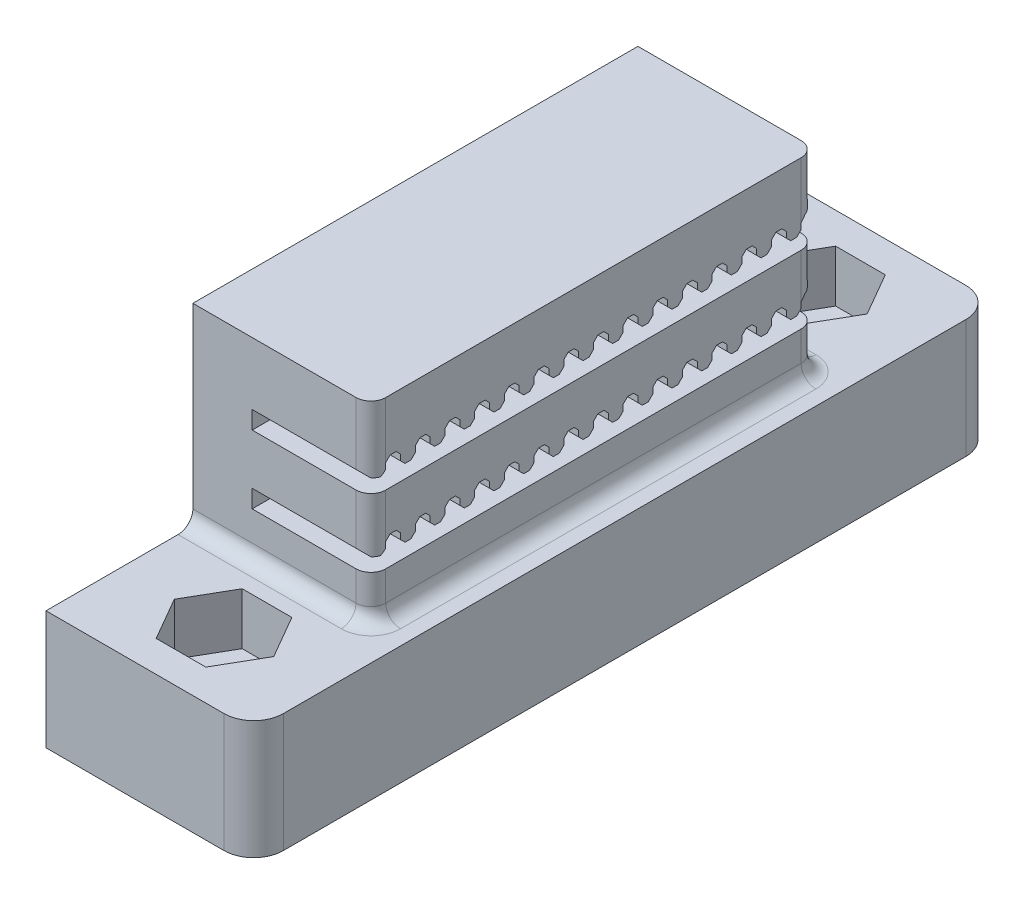
from build123d import *

# Parameters (mm, degrees)
CROQUIS1_W              = 14
CROQUIS1_H              = 50
CROQUIS1_R              = 1.65
SALIENTE_EXTRUIR1_DEPTH = 8
CORTAR_EXTRUIR1_DEPTH   = 3.5
CROQUIS3_W              = 14
CROQUIS3_H              = 30
SALIENTE_EXTRUIR3_DEPTH = 13
CORTAR_EXTRUIR2_DEPTH   = 10
CROQUIS5_W              = 30
CROQUIS5_H              = 13
CORTAR_EXTRUIR3_DEPTH   = 2
REDONDEO2_R             = 2
REDONDEO3_R             = 1
REDONDEO4_R             = 1


with BuildPart() as part:
    # Croquis1 → Saliente-Extruir1 (new body)
    with BuildSketch(Plane(origin=(0, 0, 0), x_dir=(1, 0, 0), z_dir=(0, 1, 0))):
        with Locations((7, 25)):
            Rectangle(CROQUIS1_W, CROQUIS1_H)
        with Locations((7, 45)):
            Circle(CROQUIS1_R, mode=Mode.SUBTRACT)
        with Locations((7, 5)):
            Circle(CROQUIS1_R, mode=Mode.SUBTRACT)
    extrude(amount=SALIENTE_EXTRUIR1_DEPTH)

    # Croquis2 → Cortar-Extruir1 (cut)
    with BuildSketch(Plane(origin=(0, 8, 0), x_dir=(1, 0, 0), z_dir=(0, 1, 0))):
        Polygon((10.348631561, 45), (8.674315781, 47.9), (5.325684219, 47.9), (3.651368439, 45), (5.325684219, 42.1), (8.674315781, 42.1), align=None)
        Polygon((10.348631561, 5), (8.674315781, 7.9), (5.325684219, 7.9), (3.651368439, 5), (5.325684219, 2.1), (8.674315781, 2.1), align=None)
    extrude(amount=-CORTAR_EXTRUIR1_DEPTH, mode=Mode.SUBTRACT)

    # Croquis3 → Saliente-Extruir3 (add)
    with BuildSketch(Plane(origin=(0, 8, 0), x_dir=(1, 0, 0), z_dir=(0, 1, 0))):
        with Locations((7, 24.9)):
            Rectangle(CROQUIS3_W, CROQUIS3_H)
    extrude(amount=SALIENTE_EXTRUIR3_DEPTH)

    # Croquis4 → Cortar-Extruir2 (cut)
    with BuildSketch(Plane(origin=(14, 0, 0), x_dir=(0, 0, -1), z_dir=(1, 0, 0))):
        Polygon((39.9, 12.9), (39.9, 11), (9.9, 11), (9.9, 12.2), (10.2, 11.9), (10.6, 11.9), (10.9, 12.2), (10.9, 12.6), (11.2, 12.9), (11.4, 12.9), (11.6, 12.9), (11.9, 12.6), (11.9, 12.2), (12.2, 11.9), (12.6, 11.9), (12.9, 12.2), (12.9, 12.6), (13.2, 12.9), (13.4, 12.9), (13.6, 12.9), (13.9, 12.6), (13.9, 12.2), (14.2, 11.9), (14.6, 11.9), (14.9, 12.2), (14.9, 12.6), (15.2, 12.9), (15.4, 12.9), (15.6, 12.9), (15.9, 12.6), (15.9, 12.2), (16.2, 11.9), (16.6, 11.9), (16.9, 12.2), (16.9, 12.6), (17.2, 12.9), (17.4, 12.9), (17.6, 12.9), (17.9, 12.6), (17.9, 12.2), (18.2, 11.9), (18.6, 11.9), (18.9, 12.2), (18.9, 12.6), (19.2, 12.9), (19.4, 12.9), (19.6, 12.9), (19.9, 12.6), (19.9, 12.2), (20.2, 11.9), (20.6, 11.9), (20.9, 12.2), (20.9, 12.6), (21.2, 12.9), (21.4, 12.9), (21.6, 12.9), (21.9, 12.6), (21.9, 12.2), (22.2, 11.9), (22.6, 11.9), (22.9, 12.2), (22.9, 12.6), (23.2, 12.9), (23.4, 12.9), (23.6, 12.9), (23.9, 12.6), (23.9, 12.2), (24.2, 11.9), (24.6, 11.9), (24.9, 12.2), (24.9, 12.6), (25.2, 12.9), (25.4, 12.9), (25.6, 12.9), (25.9, 12.6), (25.9, 12.2), (26.2, 11.9), (26.6, 11.9), (26.9, 12.2), (26.9, 12.6), (27.2, 12.9), (27.4, 12.9), (27.6, 12.9), (27.9, 12.6), (27.9, 12.2), (28.2, 11.9), (28.6, 11.9), (28.9, 12.2), (28.9, 12.6), (29.2, 12.9), (29.4, 12.9), (29.6, 12.9), (29.9, 12.6), (29.9, 12.2), (30.2, 11.9), (30.6, 11.9), (30.9, 12.2), (30.9, 12.6), (31.2, 12.9), (31.4, 12.9), (31.6, 12.9), (31.9, 12.6), (31.9, 12.2), (32.2, 11.9), (32.6, 11.9), (32.9, 12.2), (32.9, 12.6), (33.2, 12.9), (33.4, 12.9), (33.6, 12.9), (33.9, 12.6), (33.9, 12.2), (34.2, 11.9), (34.6, 11.9), (34.9, 12.2), (34.9, 12.6), (35.2, 12.9), (35.4, 12.9), (35.6, 12.9), (35.9, 12.6), (35.9, 12.2), (36.2, 11.9), (36.6, 11.9), (36.9, 12.2), (36.9, 12.6), (37.2, 12.9), (37.4, 12.9), (37.6, 12.9), (37.9, 12.6), (37.9, 12.2), (38.2, 11.9), (38.6, 11.9), (38.9, 12.2), (38.9, 12.6), (39.2, 12.9), (39.4, 12.9), align=None)
        Polygon((39.9, 17.5), (39.9, 15.6), (9.9, 15.6), (9.9, 16.8), (10.2, 16.5), (10.6, 16.5), (10.9, 16.8), (10.9, 17.2), (11.2, 17.5), (11.4, 17.5), (11.6, 17.5), (11.9, 17.2), (11.9, 16.8), (12.2, 16.5), (12.6, 16.5), (12.9, 16.8), (12.9, 17.2), (13.2, 17.5), (13.4, 17.5), (13.6, 17.5), (13.9, 17.2), (13.9, 16.8), (14.2, 16.5), (14.6, 16.5), (14.9, 16.8), (14.9, 17.2), (15.2, 17.5), (15.4, 17.5), (15.6, 17.5), (15.9, 17.2), (15.9, 16.8), (16.2, 16.5), (16.6, 16.5), (16.9, 16.8), (16.9, 17.2), (17.2, 17.5), (17.4, 17.5), (17.6, 17.5), (17.9, 17.2), (17.9, 16.8), (18.2, 16.5), (18.6, 16.5), (18.9, 16.8), (18.9, 17.2), (19.2, 17.5), (19.4, 17.5), (19.6, 17.5), (19.9, 17.2), (19.9, 16.8), (20.2, 16.5), (20.6, 16.5), (20.9, 16.8), (20.9, 17.2), (21.2, 17.5), (21.4, 17.5), (21.6, 17.5), (21.9, 17.2), (21.9, 16.8), (22.2, 16.5), (22.6, 16.5), (22.9, 16.8), (22.9, 17.2), (23.2, 17.5), (23.4, 17.5), (23.6, 17.5), (23.9, 17.2), (23.9, 16.8), (24.2, 16.5), (24.6, 16.5), (24.9, 16.8), (24.9, 17.2), (25.2, 17.5), (25.4, 17.5), (25.6, 17.5), (25.9, 17.2), (25.9, 16.8), (26.2, 16.5), (26.6, 16.5), (26.9, 16.8), (26.9, 17.2), (27.2, 17.5), (27.4, 17.5), (27.6, 17.5), (27.9, 17.2), (27.9, 16.8), (28.2, 16.5), (28.6, 16.5), (28.9, 16.8), (28.9, 17.2), (29.2, 17.5), (29.4, 17.5), (29.6, 17.5), (29.9, 17.2), (29.9, 16.8), (30.2, 16.5), (30.6, 16.5), (30.9, 16.8), (30.9, 17.2), (31.2, 17.5), (31.4, 17.5), (31.6, 17.5), (31.9, 17.2), (31.9, 16.8), (32.2, 16.5), (32.6, 16.5), (32.9, 16.8), (32.9, 17.2), (33.2, 17.5), (33.4, 17.5), (33.6, 17.5), (33.9, 17.2), (33.9, 16.8), (34.2, 16.5), (34.6, 16.5), (34.9, 16.8), (34.9, 17.2), (35.2, 17.5), (35.4, 17.5), (35.6, 17.5), (35.9, 17.2), (35.9, 16.8), (36.2, 16.5), (36.6, 16.5), (36.9, 16.8), (36.9, 17.2), (37.2, 17.5), (37.4, 17.5), (37.6, 17.5), (37.9, 17.2), (37.9, 16.8), (38.2, 16.5), (38.6, 16.5), (38.9, 16.8), (38.9, 17.2), (39.2, 17.5), (39.4, 17.5), align=None)
    extrude(amount=-CORTAR_EXTRUIR2_DEPTH, mode=Mode.SUBTRACT)

    # Croquis5 → Cortar-Extruir3 (cut)
    with BuildSketch(Plane(origin=(14, 0, 0), x_dir=(0, 0, -1), z_dir=(1, 0, 0))):
        with Locations((24.9, 14.5)):
            Rectangle(CROQUIS5_W, CROQUIS5_H)
    extrude(amount=-CORTAR_EXTRUIR3_DEPTH, mode=Mode.SUBTRACT)

    # Redondeo2
    redondeo2_edges = [part.edges().sort_by_distance(p)[0] for p in [
        (14, 4, -50),
        (14, 4, 0),
    ]]
    fillet(redondeo2_edges, radius=REDONDEO2_R)

    # Redondeo3
    redondeo3_edges = [part.edges().sort_by_distance(p)[0] for p in [
        (12, 19.25, -39.9),
        (12, 9.5, -39.9),
        (12, 9.5, -9.9),
        (12, 18.9, -9.9),
        (12, 13.9, -9.9),
        (12, 14.25, -39.9),
    ]]
    fillet(redondeo3_edges, radius=REDONDEO3_R)

    # Redondeo4
    redondeo4_edges = [part.edges().sort_by_distance(p)[0] for p in [
        (5.5, 8, -39.9),
        (12, 8, -24.9),
        (11.707106781, 8, -39.607106781),
        (11.707106781, 8, -10.192893219),
        (5.5, 8, -9.9),
    ]]
    fillet(redondeo4_edges, radius=REDONDEO4_R)


solid = part.part
